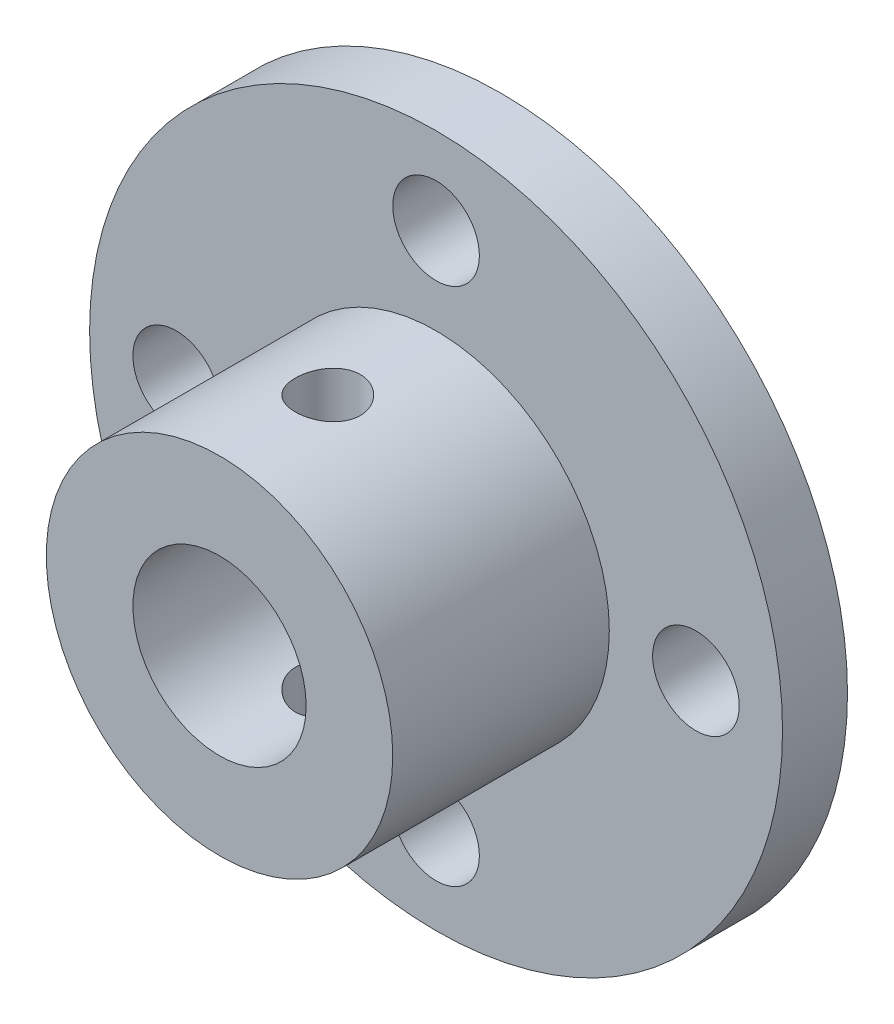
from build123d import *

# Parameters (mm, degrees)
SCHIZZO1_R                    = 16
ESTRUSIONE_ESTRUSIONE2_DEPTH  = 3
SCHIZZO2_R                    = 8
ESTRUSIONE_ESTRUSIONE3_DEPTH  = 10
SCHIZZO3_R                    = 4
SCHIZZO3_R_2                  = 2
TAGLIO_ESTRUSIONE1_DEPTH      = 1
TAGLIO_ESTRUSIONE1_DEPTH_BACK = 14
SCHIZZO4_R                    = 1.5
TAGLIO_ESTRUSIONE2_DEPTH      = 17
TAGLIO_ESTRUSIONE2_DEPTH_BACK = 17


with BuildPart() as part:
    # Schizzo1 → Estrusione-Estrusione2 (new body)
    with BuildSketch(Plane.XY):
        Circle(SCHIZZO1_R)
    extrude(amount=ESTRUSIONE_ESTRUSIONE2_DEPTH)

    # Schizzo2 → Estrusione-Estrusione3 (add)
    with BuildSketch(Plane.XY.offset(3)):
        Circle(SCHIZZO2_R)
    extrude(amount=ESTRUSIONE_ESTRUSIONE3_DEPTH)

    # Schizzo3 → Taglio-Estrusione1 (cut, two sides)
    with BuildSketch(Plane.XY.offset(13)) as taglio_estrusione1_sk:
        Circle(SCHIZZO3_R)
        with Locations((12, 0)):
            Circle(SCHIZZO3_R_2)
        with Locations((0, 12)):
            Circle(SCHIZZO3_R_2)
        with Locations((-12, 0)):
            Circle(SCHIZZO3_R_2)
        with Locations((0, -12)):
            Circle(SCHIZZO3_R_2)
    extrude(amount=TAGLIO_ESTRUSIONE1_DEPTH, mode=Mode.SUBTRACT)
    extrude(taglio_estrusione1_sk.sketch, amount=-TAGLIO_ESTRUSIONE1_DEPTH_BACK, mode=Mode.SUBTRACT)

    # Schizzo4 → Taglio-Estrusione2 (cut, two sides)
    with BuildSketch(Plane(origin=(0, 0, 0), x_dir=(1, 0, 0), z_dir=(0, 1, 0))) as taglio_estrusione2_sk:
        with Locations((0, -8)):
            Circle(SCHIZZO4_R)
    extrude(amount=TAGLIO_ESTRUSIONE2_DEPTH, mode=Mode.SUBTRACT)
    extrude(taglio_estrusione2_sk.sketch, amount=-TAGLIO_ESTRUSIONE2_DEPTH_BACK, mode=Mode.SUBTRACT)


solid = part.part
